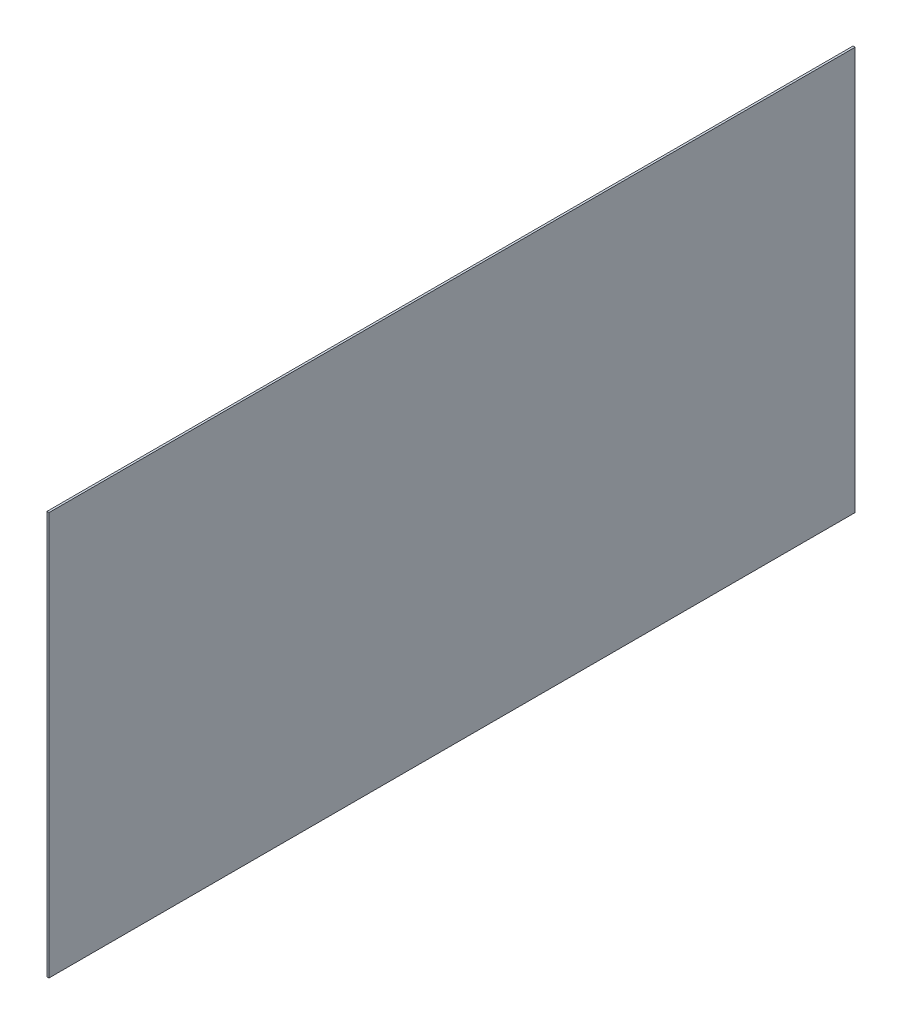
from build123d import *

# Parameters (mm, degrees)
SKETCH1_W           = 1828.8
SKETCH1_H           = 914.4
BOSS_EXTRUDE1_DEPTH = 4.7625


with BuildPart() as part:
    # Sketch1 → Boss-Extrude1 (new body)
    with BuildSketch(Plane(origin=(0, 0, 0), x_dir=(0, 0, -1), z_dir=(1, 0, 0))):
        with Locations((914.4, 457.2)):
            Rectangle(SKETCH1_W, SKETCH1_H)
    extrude(amount=BOSS_EXTRUDE1_DEPTH)


solid = part.part
